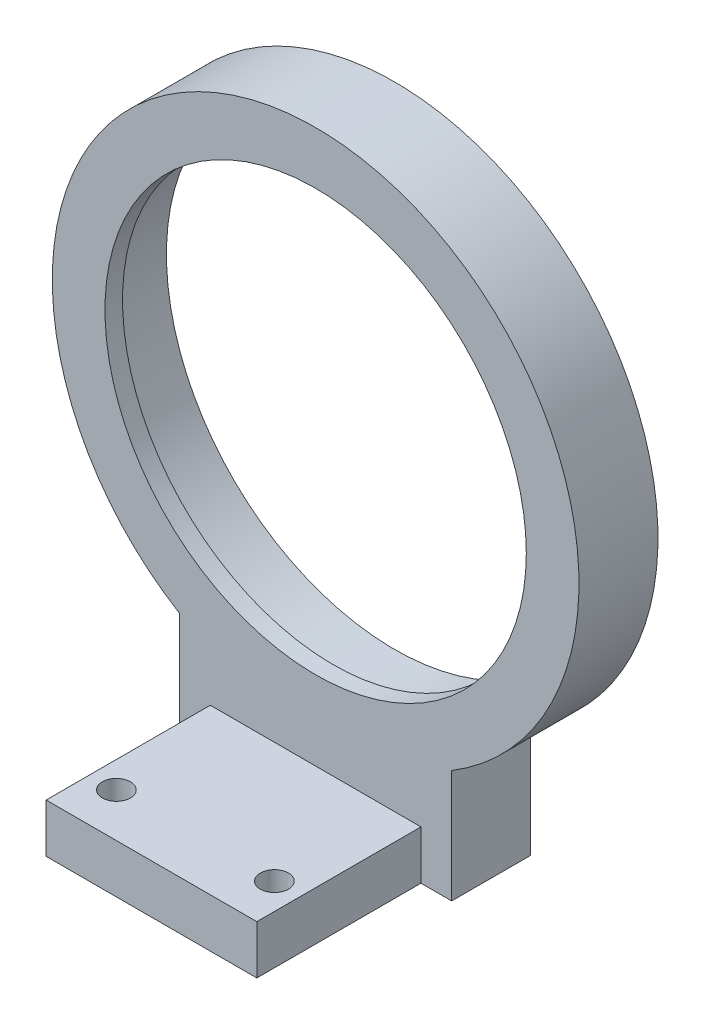
from build123d import *

# Parameters (mm, degrees)
SKETCH_1_R          = 26
EXTRUDE_1_DEPTH     = 7
SKETCH_4_R          = 30
SKETCH_4_R_2        = 24
EXTRUDE_4_DEPTH     = 2
SKETCH_5_W          = 24
SKETCH_5_H          = 5
EXTRUDE_5_DEPTH     = 20.7
EXTRUDE_8_DEPTH     = 2
SKETCH_9_R          = 1.6
CUT_EXTRUDE_1_DEPTH = 6
EXTRUDE_9_DEPTH     = 0.56
SKETCH_11_R         = 1.6
CUT_EXTRUDE_2_DEPTH = 25


with BuildPart() as part:
    # 草图1 → 凸台-拉伸1 (new body)
    with BuildSketch(Plane.XY):
        with BuildLine():
            Line((-15.5, -38), (15.5, -38))
            Line((15.5, -38), (15.5, -25.685599078))
            ThreePointArc((15.5, -25.685599078), (0, 30), (-15.5, -25.685599078))
            Line((-15.5, -25.685599078), (-15.5, -38))
        make_face()
        Circle(SKETCH_1_R, mode=Mode.SUBTRACT)
    extrude(amount=EXTRUDE_1_DEPTH)

    # 草图4 → 凸台-拉伸4 (add)
    with BuildSketch(Plane.XY.offset(7)):
        Circle(SKETCH_4_R)
        Circle(SKETCH_4_R_2, mode=Mode.SUBTRACT)
    extrude(amount=EXTRUDE_4_DEPTH)

    # 草图5 → 凸台-拉伸5 (add)
    with BuildSketch(Plane.XY.offset(7)):
        with Locations((0, -35.5)):
            Rectangle(SKETCH_5_W, SKETCH_5_H)
    extrude(amount=EXTRUDE_5_DEPTH)

    # 草图6 → 凸台-拉伸8 (add)
    with BuildSketch(Plane.XY.offset(7)):
        with BuildLine():
            Line((15.5, -38), (15.5, -25.685599078))
            ThreePointArc((15.5, -25.685599078), (0, -30), (-15.5, -25.685599078))
            Line((-15.5, -25.685599078), (-15.5, -38))
            Line((-15.5, -38), (-12, -38))
            Line((-12, -38), (-12, -33))
            Line((-12, -33), (12, -33))
            Line((12, -33), (12, -38))
            Line((12, -38), (15.5, -38))
        make_face()
    extrude(amount=EXTRUDE_8_DEPTH)

    # 草图9 → 切除-拉伸1 (cut, through all)
    with BuildSketch(Plane(origin=(0, -33, 0), x_dir=(1, 0, 0), z_dir=(0, 1, 0))):
        with Locations((-9, -22.7)):
            Circle(SKETCH_9_R)
        with Locations((9, -22.7)):
            Circle(SKETCH_9_R)
    extrude(amount=-CUT_EXTRUDE_1_DEPTH, mode=Mode.SUBTRACT)

    # 草图10 → 凸台-拉伸9 (add)
    with BuildSketch(Plane.XZ.offset(38)):
        Polygon((15.5, 0), (15.5, 9), (12, 9), (12, 27.7), (-12, 27.7), (-12, 9), (-15.5, 9), (-15.5, 0), align=None)
    extrude(amount=EXTRUDE_9_DEPTH)

    # 草图11 → 切除-拉伸2 (cut)
    with BuildSketch(Plane(origin=(0, -33, 0), x_dir=(1, 0, 0), z_dir=(0, 1, 0))):
        with Locations((9, -22.7)):
            Circle(SKETCH_11_R)
        with Locations((-9, -22.7)):
            Circle(SKETCH_11_R)
    extrude(amount=-CUT_EXTRUDE_2_DEPTH, mode=Mode.SUBTRACT)


solid = part.part
